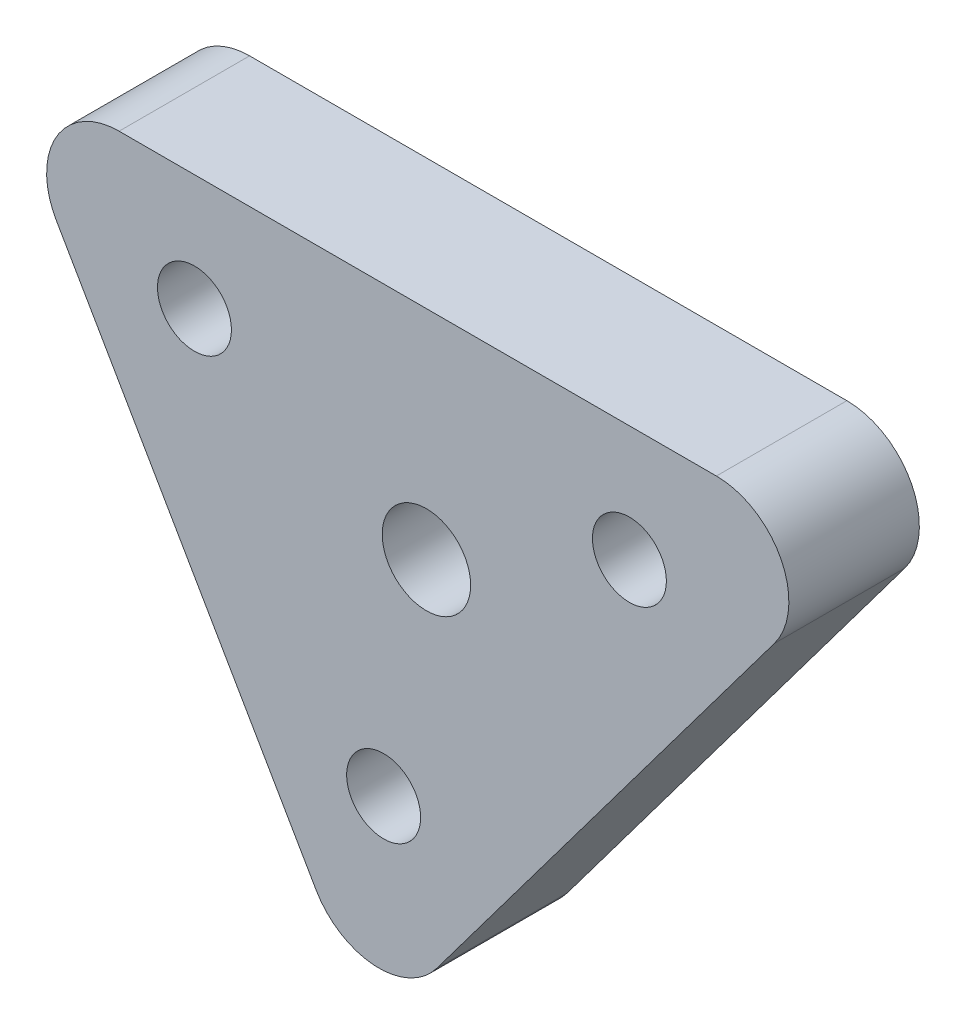
from build123d import *

# Parameters (mm, degrees)
SKETCH_1_R      = 2.55
SKETCH_1_R_2    = 3.05
EXTRUDE_1_DEPTH = 9
FILLET_1_R      = 5


with BuildPart() as part:
    # 草图1 → 凸台-拉伸1 (new body)
    with BuildSketch(Plane.XY):
        Polygon((-54.053450796, 27.320514858), (5.802955665, 27.320514858), (-28.018037849, -17.774143161), align=None)
        with Locations((-40.197044335, 19.320514858)):
            Circle(SKETCH_1_R, mode=Mode.SUBTRACT)
        with Locations((-27.148108815, -3.280904448)):
            Circle(SKETCH_1_R, mode=Mode.SUBTRACT)
        with Locations((-10.197044335, 19.320514858)):
            Circle(SKETCH_1_R, mode=Mode.SUBTRACT)
        with Locations((-24.197044335, 12.320514858)):
            Circle(SKETCH_1_R_2, mode=Mode.SUBTRACT)
    extrude(amount=EXTRUDE_1_DEPTH)

    # 圆角1
    fillet_1_edges = [part.edges().sort_by_distance(p)[0] for p in [
        (-54.053450796, 27.320514858, 4.5),
        (5.802955665, 27.320514858, 4.5),
        (-28.018037849, -17.774143161, 4.5),
    ]]
    fillet(fillet_1_edges, radius=FILLET_1_R)


solid = part.part
